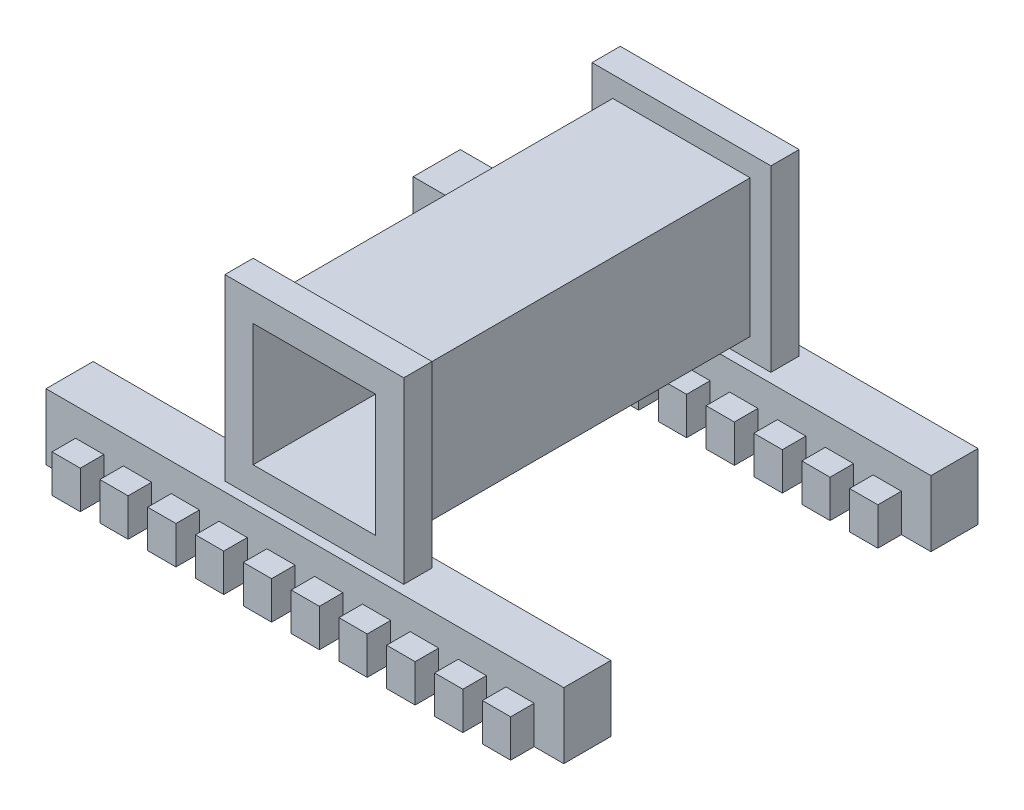
from build123d import *

# Parameters (mm, degrees)
EXTRUDE_1_DEPTH      = 21
SKETCH_1_3_W         = 13
SKETCH_1_3_H         = 13
CUT_EXTRUDE_1_DEPTH  = 21
SKETCH_1_12_W        = 19
SKETCH_1_12_H        = 19
SKETCH_1_12_W_2      = 14.6
SKETCH_1_12_H_2      = 14.6
SKETCH_1_12_W_3      = 13
SKETCH_1_12_H_3      = 13
CUT_EXTRUDE_6_DEPTH  = 18
CUT_EXTRUDE_7_DEPTH  = 14.5
SKETCH_4_W           = 3.504900739
SKETCH_4_H           = 7
SKETCH_4_W_2         = 3.5
EXTRUDE_2_DEPTH      = 27.5
SKETCH_5_W           = 3
SKETCH_5_H           = 4
CUT_EXTRUDE_8_DEPTH  = 2.5
SKETCH_7_W           = 3
SKETCH_7_H           = 4
CUT_EXTRUDE_9_DEPTH  = 2.5
SKETCH_9_W           = 3
SKETCH_9_H           = 4
CUT_EXTRUDE_10_DEPTH = 2.5
SKETCH_10_W          = 3
SKETCH_10_H          = 4
CUT_EXTRUDE_11_DEPTH = 2.5


with BuildPart() as part:
    # 草图1 → 凸台-拉伸1 (new, symmetric)
    with BuildSketch(Plane.XY):
        Polygon((9.5, 9.5), (-9.5, 9.5), (-9.5, -9.5), (-27.5, -9.5), (-27.5, -16.5), (27.5, -16.5), (27.5, -9.5), (9.5, -9.5), align=None)
    extrude(amount=EXTRUDE_1_DEPTH, both=True)

    # 草图1<3> → 切除-拉伸1 (cut, symmetric)
    with BuildSketch(Plane.XY):
        Rectangle(SKETCH_1_3_W, SKETCH_1_3_H)
    extrude(amount=CUT_EXTRUDE_1_DEPTH, both=True, mode=Mode.SUBTRACT)

    # 草图1<12> → 切除-拉伸6 (cut, symmetric)
    # profile 1 of 2: a face of its own
    with BuildSketch(Plane.XY):
        Rectangle(SKETCH_1_12_W, SKETCH_1_12_H)
        Rectangle(SKETCH_1_12_W_2, SKETCH_1_12_H_2, mode=Mode.SUBTRACT)
    # profile 2 of 2: a face of its own
    with BuildSketch(Plane.XY):
        Rectangle(SKETCH_1_12_W_3, SKETCH_1_12_H_3)
    extrude(amount=CUT_EXTRUDE_6_DEPTH, both=True, mode=Mode.SUBTRACT)

    # 草图1<13> → 切除-拉伸7 (cut, symmetric)
    with BuildSketch(Plane.XY):
        Polygon((9.5, -9.5), (-9.5, -9.5), (-27.5, -9.5), (-27.5, -16.5), (27.5, -16.5), (27.5, -9.5), align=None)
    extrude(amount=CUT_EXTRUDE_7_DEPTH, both=True, mode=Mode.SUBTRACT)

    # 草图4 → 凸台-拉伸2 (add, symmetric)
    with BuildSketch(Plane(origin=(0, 0, 0), x_dir=(0, 0, -1), z_dir=(1, 0, 0))):
        with Locations((-22.752450369, -13)):
            Rectangle(SKETCH_4_W, SKETCH_4_H)
        with Locations((22.75, -13)):
            Rectangle(SKETCH_4_W_2, SKETCH_4_H)
    extrude(amount=EXTRUDE_2_DEPTH, both=True)

    # 草图5 → 切除-拉伸8 (cut)
    with BuildSketch(Plane(origin=(0, 0, -24.5), x_dir=(-1, 0, 0), z_dir=(0, 0, -1))):
        Polygon((-19.28, -12.503647236), (-16.28, -12.503647236), (-16.28, -16.5), (-14.213019691, -16.5), (-14.213019691, -12.503647236), (-11.186980309, -12.503647236), (-11.186980309, -16.5), (-9.12, -16.5), (-9.12, -12.503647236), (-6.12, -12.503647236), (-6.12, -16.5), (1.038031299, -16.5), (1.038031299, -12.495586292), (4.04, -12.495586292), (4.04, -16.5), (6.12, -16.5), (6.12, -12.5), (9.12, -12.5), (9.12, -16.5), (11.198647667, -16.5), (11.198647667, -12.5), (14.201352333, -12.5), (14.201352333, -16.5), (21.36, -16.5), (21.36, -12.487022539), (24.35864906, -12.487022539), (24.35864906, -16.5), (27.5, -16.5), (27.5, -9.5), (-27.5, -9.5), (-27.5, -16.5), (-24.36, -16.5), (-24.36, -12.503647236), (-21.36, -12.503647236), (-21.36, -16.5), (-19.28, -16.5), align=None)
        with Locations((17.78, -14.493511269)):
            Rectangle(SKETCH_5_W, SKETCH_5_H, mode=Mode.SUBTRACT)
        with Locations((-2.54, -14.497793146)):
            Rectangle(SKETCH_5_W, SKETCH_5_H, mode=Mode.SUBTRACT)
    extrude(amount=-CUT_EXTRUDE_8_DEPTH, mode=Mode.SUBTRACT)

    # 草图7 → 切除-拉伸9 (cut)
    with BuildSketch(Plane.XY.offset(-14.5)):
        Polygon((24.36, -16.5), (27.5, -16.5), (27.5, -9.5), (-27.5, -9.5), (-27.5, -16.5), (-24.35864906, -16.5), (-24.35864906, -12.487022539), (-21.36, -12.487022539), (-21.36, -16.5), (-14.201352333, -16.5), (-14.201352333, -12.5), (-11.198647667, -12.5), (-11.198647667, -16.5), (-9.12, -16.5), (-9.12, -12.5), (-6.12, -12.5), (-6.12, -16.5), (-4.04, -16.5), (-4.04, -12.495586292), (-1.038031299, -12.495586292), (-1.038031299, -16.5), (6.12, -16.5), (6.12, -12.503647236), (9.12, -12.503647236), (9.12, -16.5), (11.186980309, -16.5), (11.186980309, -12.503647236), (14.213019691, -12.503647236), (14.213019691, -16.5), (16.28, -16.5), (16.28, -12.503647236), (19.28, -12.503647236), (19.28, -16.5), (21.36, -16.5), (21.36, -12.503647236), (24.36, -12.503647236), align=None)
        with Locations((-17.78, -14.493511269)):
            Rectangle(SKETCH_7_W, SKETCH_7_H, mode=Mode.SUBTRACT)
        with Locations((2.54, -14.497793146)):
            Rectangle(SKETCH_7_W, SKETCH_7_H, mode=Mode.SUBTRACT)
    extrude(amount=-CUT_EXTRUDE_9_DEPTH, mode=Mode.SUBTRACT)

    # 草图9 → 切除-拉伸10 (cut)
    with BuildSketch(Plane(origin=(0, 0, 14.5), x_dir=(-1, 0, 0), z_dir=(0, 0, -1))):
        Polygon((27.5, -9.5), (-27.5, -9.5), (-27.5, -16.5), (-24.36, -16.5), (-24.36, -12.503647236), (-21.36, -12.503647236), (-21.36, -16.5), (-19.28, -16.5), (-19.28, -12.503647236), (-16.28, -12.503647236), (-16.28, -16.5), (-14.213019691, -16.5), (-14.213019691, -12.503647236), (-11.186980309, -12.503647236), (-11.186980309, -16.5), (-9.12, -16.5), (-9.12, -12.503647236), (-6.12, -12.503647236), (-6.12, -16.5), (1.038031299, -16.5), (1.038031299, -12.495586292), (4.04, -12.495586292), (4.04, -16.5), (6.12, -16.5), (6.12, -12.5), (9.12, -12.5), (9.12, -16.5), (11.198647667, -16.5), (11.198647667, -12.5), (14.201352333, -12.5), (14.201352333, -16.5), (21.36, -16.5), (21.36, -12.487022539), (24.35864906, -12.487022539), (24.35864906, -16.5), (27.5, -16.5), align=None)
        with Locations((-2.54, -14.497793146)):
            Rectangle(SKETCH_9_W, SKETCH_9_H, mode=Mode.SUBTRACT)
        with Locations((17.78, -14.493511269)):
            Rectangle(SKETCH_9_W, SKETCH_9_H, mode=Mode.SUBTRACT)
    extrude(amount=-CUT_EXTRUDE_10_DEPTH, mode=Mode.SUBTRACT)

    # 草图10 → 切除-拉伸11 (cut)
    with BuildSketch(Plane.XY.offset(24.504900739)):
        Polygon((27.5, -9.5), (-27.5, -9.5), (-27.5, -16.5), (-24.35864906, -16.5), (-24.35864906, -12.487022539), (-21.36, -12.487022539), (-21.36, -16.5), (-14.201352333, -16.5), (-14.201352333, -12.5), (-11.198647667, -12.5), (-11.198647667, -16.5), (-9.12, -16.5), (-9.12, -12.5), (-6.12, -12.5), (-6.12, -16.5), (-4.04, -16.5), (-4.04, -12.495586292), (-1.038031299, -12.495586292), (-1.038031299, -16.5), (6.12, -16.5), (6.12, -12.503647236), (9.12, -12.503647236), (9.12, -16.5), (11.186980309, -16.5), (11.186980309, -12.503647236), (14.213019691, -12.503647236), (14.213019691, -16.5), (16.28, -16.5), (16.28, -12.503647236), (19.28, -12.503647236), (19.28, -16.5), (21.36, -16.5), (21.36, -12.503647236), (24.36, -12.503647236), (24.36, -16.5), (27.5, -16.5), align=None)
        with Locations((-17.78, -14.493511269)):
            Rectangle(SKETCH_10_W, SKETCH_10_H, mode=Mode.SUBTRACT)
        with Locations((2.54, -14.497793146)):
            Rectangle(SKETCH_10_W, SKETCH_10_H, mode=Mode.SUBTRACT)
    extrude(amount=-CUT_EXTRUDE_11_DEPTH, mode=Mode.SUBTRACT)


solid = part.part
